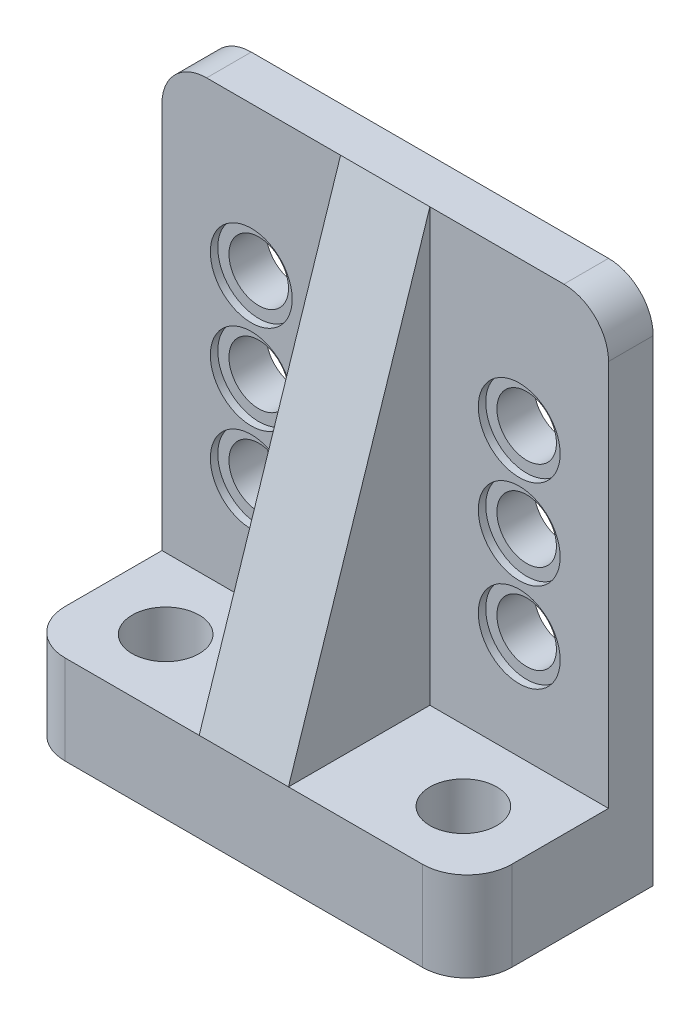
from build123d import *

# Parameters (mm, degrees)
ESQUISSE1_W                  = 30
ESQUISSE1_H                  = 35
BOSS_EXTRU_1_DEPTH           = 3
ESQUISSE2_R                  = 2
ENL_V_MAT_EXTRU_1_DEPTH      = 1
ENL_V_MAT_EXTRU_1_DEPTH_BACK = 4
ESQUISSE3_W                  = 30
ESQUISSE3_H                  = 6
BOSS_EXTRU_2_DEPTH           = 9.5
ESQUISSE4_R                  = 2.25
ENL_V_MAT_EXTRU_2_DEPTH      = 30
ENL_V_MAT_EXTRU_2_DEPTH_BACK = 7
BOSS_EXTRU_3_START           = -18
BOSS_EXTRU_3_DEPTH           = 6
CONG_1_R                     = 3
ESQUISSE6_R                  = 2.75
ENL_V_MAT_EXTRU_3_DEPTH      = 0.5


with BuildPart() as part:
    # Esquisse1 → Boss.-Extru.1 (new body)
    with BuildSketch(Plane.XY):
        with Locations((15, 17.5)):
            Rectangle(ESQUISSE1_W, ESQUISSE1_H)
    extrude(amount=BOSS_EXTRU_1_DEPTH)

    # Esquisse2 → Enlèv. mat.-Extru.1 (cut, two sides)
    with BuildSketch(Plane.XY.offset(3)) as enl_v_mat_extru_1_sk:
        with Locations((6, 25)):
            Circle(ESQUISSE2_R)
        with Locations((24, 25)):
            Circle(ESQUISSE2_R)
        with Locations((24, 13)):
            Circle(ESQUISSE2_R)
        with Locations((6, 13)):
            Circle(ESQUISSE2_R)
        with Locations((6, 19)):
            Circle(ESQUISSE2_R)
        with Locations((24, 19)):
            Circle(ESQUISSE2_R)
    extrude(amount=ENL_V_MAT_EXTRU_1_DEPTH, mode=Mode.SUBTRACT)
    extrude(enl_v_mat_extru_1_sk.sketch, amount=-ENL_V_MAT_EXTRU_1_DEPTH_BACK, mode=Mode.SUBTRACT)

    # Esquisse3 → Boss.-Extru.2 (add)
    with BuildSketch(Plane.XY.offset(3)):
        with Locations((15, 3)):
            Rectangle(ESQUISSE3_W, ESQUISSE3_H)
    extrude(amount=BOSS_EXTRU_2_DEPTH)

    # Esquisse4 → Enlèv. mat.-Extru.2 (cut, two sides)
    with BuildSketch(Plane(origin=(0, 6, 0), x_dir=(1, 0, 0), z_dir=(0, 1, 0))) as enl_v_mat_extru_2_sk:
        with Locations((25, -7.75)):
            Circle(ESQUISSE4_R)
        with Locations((5, -7.75)):
            Circle(ESQUISSE4_R)
    extrude(amount=ENL_V_MAT_EXTRU_2_DEPTH, mode=Mode.SUBTRACT)
    extrude(enl_v_mat_extru_2_sk.sketch, amount=-ENL_V_MAT_EXTRU_2_DEPTH_BACK, mode=Mode.SUBTRACT)

    # Esquisse5 → Boss.-Extru.3 (add)
    with BuildSketch(Plane(origin=(30, 0, 0), x_dir=(0, 0, -1), z_dir=(1, 0, 0)).offset(BOSS_EXTRU_3_START)):
        Polygon((-12.5, 6), (-3, 35), (-3, 6), align=None)
    extrude(amount=BOSS_EXTRU_3_DEPTH)

    # Congé1
    cong_1_edges = [part.edges().sort_by_distance(p)[0] for p in [
        (0, 3, 12.5),
        (30, 3, 12.5),
        (0, 35, 1.5),
        (30, 35, 1.5),
    ]]
    fillet(cong_1_edges, radius=CONG_1_R)

    # Esquisse6 → Enlèv. mat.-Extru.3 (cut)
    with BuildSketch(Plane.XY.offset(3)):
        with Locations((24, 25)):
            Circle(ESQUISSE6_R)
        with Locations((24, 19)):
            Circle(ESQUISSE6_R)
        with Locations((24, 13)):
            Circle(ESQUISSE6_R)
        with Locations((6, 13)):
            Circle(ESQUISSE6_R)
        with Locations((6, 19)):
            Circle(ESQUISSE6_R)
        with Locations((6, 25)):
            Circle(ESQUISSE6_R)
    extrude(amount=-ENL_V_MAT_EXTRU_3_DEPTH, mode=Mode.SUBTRACT)


solid = part.part
